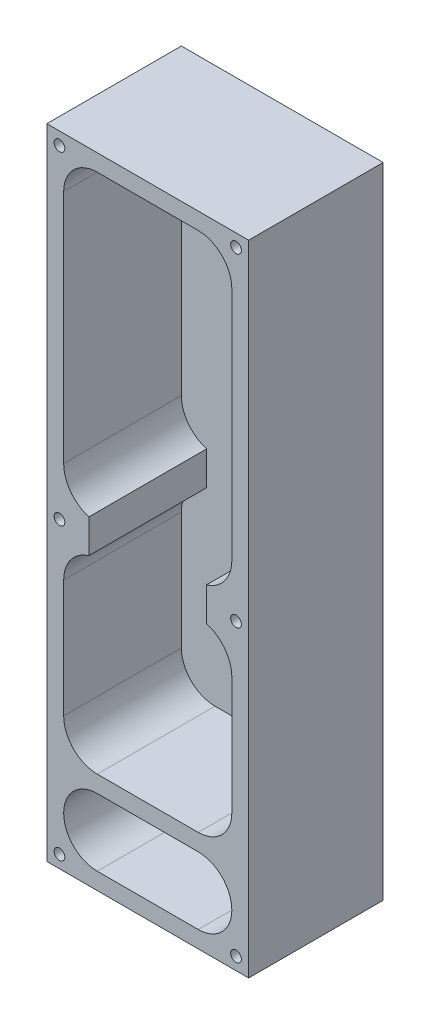
from build123d import *

# Parameters (mm, degrees)
SKETCH1_W              = 76.2
SKETCH1_H              = 241.3
SKETCH1_W_2            = 63.5
SKETCH1_H_2            = 228.6
BOSS_EXTRUDE1_DEPTH    = 44.45
FILLET1_R              = 12.7
SKETCH2_W              = 76.2
SKETCH2_H              = 241.3
BOSS_EXTRUDE2_DEPTH    = 6.35
BOSS_EXTRUDE3_DEPTH    = 44.45
F_10_32_TAPPED_HOLE1_D = 4.0386
BOSS_EXTRUDE4_DEPTH    = 44.45


with BuildPart() as part:
    # Sketch1 → Boss-Extrude1 (new body)
    with BuildSketch(Plane.XY):
        with Locations((38.1, -120.65)):
            Rectangle(SKETCH1_W, SKETCH1_H)
        with Locations((38.1, -120.65)):
            Rectangle(SKETCH1_W_2, SKETCH1_H_2, mode=Mode.SUBTRACT)
    extrude(amount=BOSS_EXTRUDE1_DEPTH)

    # Fillet1
    fillet1_edges = [part.edges().sort_by_distance(p)[0] for p in [
        (6.35, -6.35, 22.225),
        (6.35, -234.95, 22.225),
        (69.85, -234.95, 22.225),
        (69.85, -6.35, 22.225),
    ]]
    fillet(fillet1_edges, radius=FILLET1_R)

    # Sketch2 → Boss-Extrude2 (add)
    with BuildSketch(Plane(origin=(0, 0, 0), x_dir=(-1, 0, 0), z_dir=(0, 0, -1))):
        with Locations((-38.1, -120.65)):
            Rectangle(SKETCH2_W, SKETCH2_H)
    extrude(amount=BOSS_EXTRUDE2_DEPTH)

    # Sketch3 → Boss-Extrude3 (add)
    with BuildSketch(Plane.XY.offset(44.45)):
        with BuildLine():
            Line((60.325, -120.65), (60.325, -133.35))
            ThreePointArc((60.325, -133.35), (67.204166667, -138.1125), (69.85, -146.05))
            Line((69.85, -146.05), (69.85, -107.95))
            ThreePointArc((69.85, -107.95), (67.204166667, -115.8875), (60.325, -120.65))
        make_face()
    boss_extrude3 = extrude(amount=-BOSS_EXTRUDE3_DEPTH)

    # Mirror1: Boss-Extrude3 across plane
    add(boss_extrude3.mirror(Plane.ZY.offset(-38.1)))

    # #10-32 Tapped Hole1 (through all)
    with Locations(Plane.XY.offset(44.45)):
        with Locations((4.7625, -4.7625), (71.4375, -4.7625), (71.4375, -127), (4.7625, -127), (4.7625, -236.5375), (71.4375, -236.5375)):
            Hole(F_10_32_TAPPED_HOLE1_D / 2)

    # Sketch8 → Boss-Extrude4 (add)
    with BuildSketch(Plane.XY.offset(44.45)):
        with BuildLine():
            Line((19.05, -209.55), (57.15, -209.55))
            ThreePointArc((57.15, -209.55), (66.130256121, -213.269743879), (69.85, -222.25))
            Line((69.85, -222.25), (69.85, -190.5))
            ThreePointArc((69.85, -190.5), (66.130256121, -199.480256121), (57.15, -203.2))
            Line((57.15, -203.2), (19.05, -203.2))
            ThreePointArc((19.05, -203.2), (10.069743879, -199.480256121), (6.35, -190.5))
            Line((6.35, -190.5), (6.35, -222.25))
            ThreePointArc((6.35, -222.25), (10.069743879, -213.269743879), (19.05, -209.55))
        make_face()
    extrude(amount=-BOSS_EXTRUDE4_DEPTH)


solid = part.part
